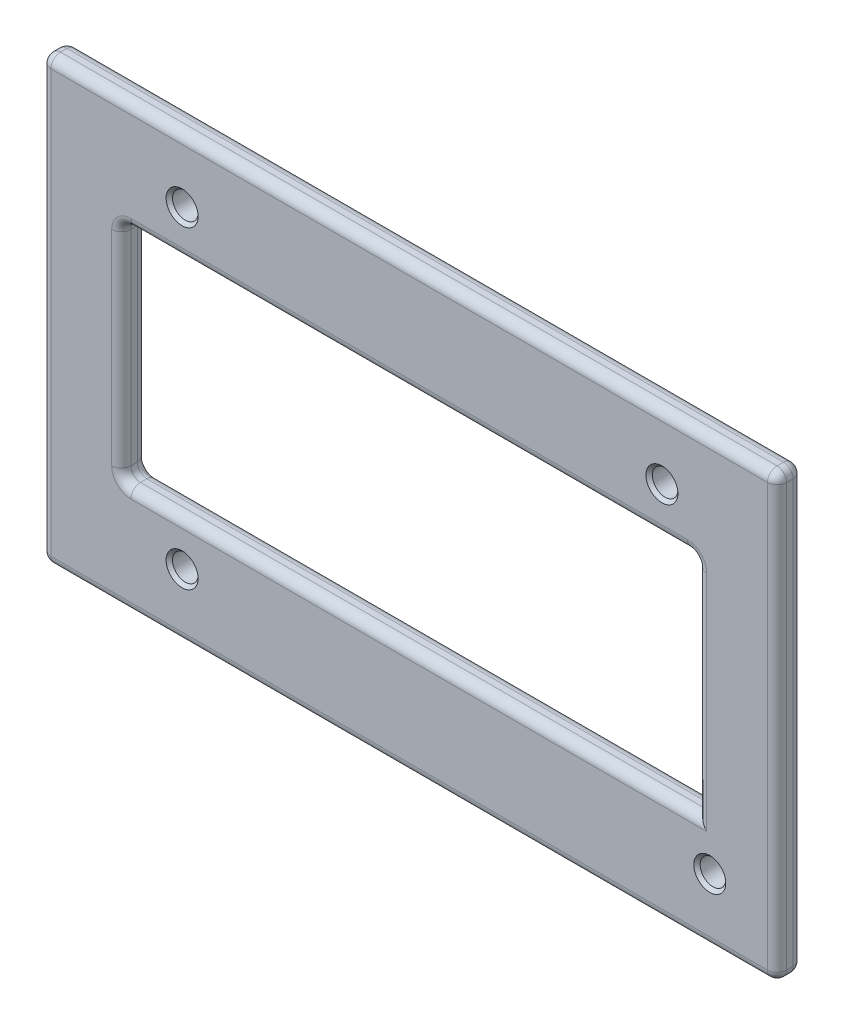
from build123d import *

# Parameters (mm, degrees)
SKETCH1_W           = 115
SKETCH1_H           = 69
BOSS_EXTRUDE1_DEPTH = 4
SKETCH2_R           = 2
CUT_EXTRUDE1_DEPTH  = 4
SKETCH3_W           = 90
SKETCH3_H           = 35
CUT_EXTRUDE2_DEPTH  = 4
CHAMFER1_SIZE       = 0.5
FILLET1_R           = 1.5


with BuildPart() as part:
    # Sketch1 → Boss-Extrude1 (new body)
    with BuildSketch(Plane.XY):
        Rectangle(SKETCH1_W, SKETCH1_H)
    extrude(amount=BOSS_EXTRUDE1_DEPTH)

    # Sketch2 → Cut-Extrude1 (cut)
    with BuildSketch(Plane.XY.offset(4)):
        with Locations((-35.5, 24.5)):
            Circle(SKETCH2_R)
        with Locations((39.5, 24.5)):
            Circle(SKETCH2_R)
        with Locations((46.979, -24.5)):
            Circle(SKETCH2_R)
        with Locations((-35.5, -24.5)):
            Circle(SKETCH2_R)
    extrude(amount=-CUT_EXTRUDE1_DEPTH, mode=Mode.SUBTRACT)

    # Sketch3 → Cut-Extrude2 (cut)
    with BuildSketch(Plane.XY.offset(4)):
        Rectangle(SKETCH3_W, SKETCH3_H)
    extrude(amount=-CUT_EXTRUDE2_DEPTH, mode=Mode.SUBTRACT)

    # Chamfer1
    chamfer1_edges = [part.edges().sort_by_distance(p)[0] for p in [
        (44.979, -24.5, 4),
        (-37.5, 24.5, 4),
        (-37.5, -24.5, 4),
        (37.5, 24.5, 4),
    ]]
    chamfer(chamfer1_edges, length=CHAMFER1_SIZE)

    # Fillet1
    fillet1_edges = [part.edges().sort_by_distance(p)[0] for p in [
        (-57.5, 0, 4),
        (0, -34.5, 4),
        (45, 0, 0),
        (45, 17.5, 2),
        (0, -17.5, 0),
        (-45, 0, 0),
        (-45, -17.5, 2),
        (0, 17.5, 0),
        (-45, 17.5, 2),
        (45, 0, 4),
        (0, 17.5, 4),
        (-45, 0, 4),
        (0, -17.5, 4),
        (57.5, 0, 4),
        (0, -34.5, 0),
        (-57.5, 0, 0),
        (0, 34.5, 0),
        (57.5, 0, 0),
        (57.5, -34.5, 2),
        (-57.5, -34.5, 2),
        (-57.5, 34.5, 2),
        (57.5, 34.5, 2),
        (0, 34.5, 4),
    ]]
    fillet(fillet1_edges, radius=FILLET1_R)


solid = part.part
